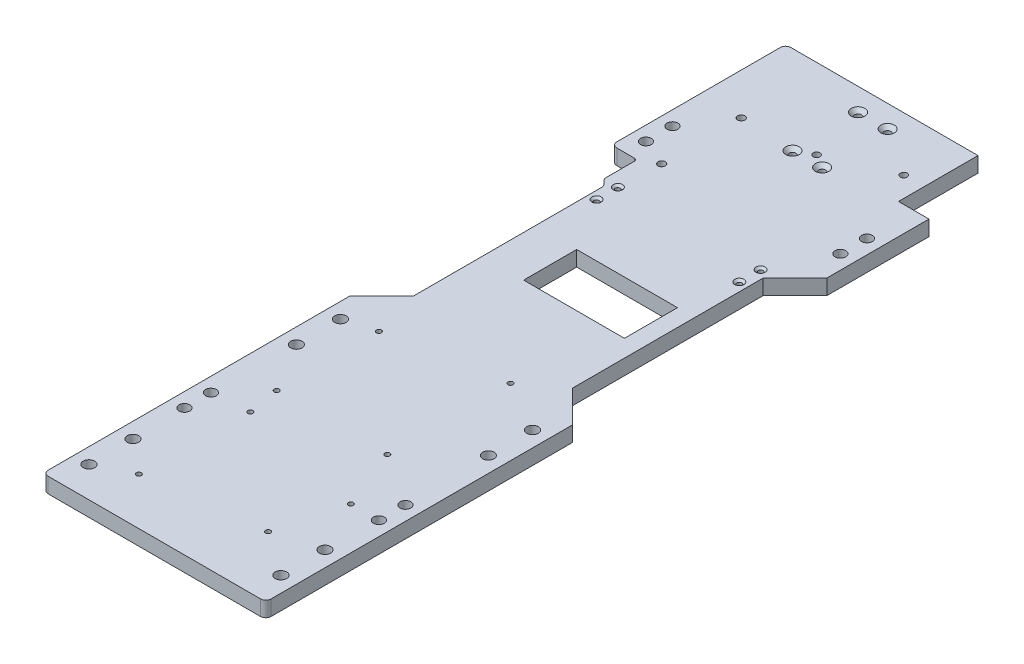
from build123d import *

# Parameters (mm, degrees)
SKETCH1_W                                         = 106.7435
SKETCH1_H                                         = 355.6
BOSS_EXTRUDE1_DEPTH                               = 7.3152
F_6_0_204_DIAMETER_HOLE1_D                        = 5.1816
FILLET1_R                                         = 2.54
MIRROR3_COPY_1_D                                  = 5.1816
CUT_EXTRUDE1_DEPTH                                = 8.3152
CSK_FOR_M2_FLAT_HEAD_MACHINE_SCREW7_D             = 2.4
CSK_FOR_M2_FLAT_HEAD_MACHINE_SCREW7_DEPTH         = 7.3152
CSK_FOR_M2_FLAT_HEAD_MACHINE_SCREW7_CSINK_D       = 4.4
CSK_FOR_M2_FLAT_HEAD_MACHINE_SCREW7_CSINK_ANGLE   = 90
CSK_FOR_4_FLAT_HEAD_SOCKET_CAP_SCREW2_D           = 3.2639
CSK_FOR_4_FLAT_HEAD_SOCKET_CAP_SCREW2_DEPTH       = 7.3152
CSK_FOR_4_FLAT_HEAD_SOCKET_CAP_SCREW2_CSINK_D     = 6.477
CSK_FOR_4_FLAT_HEAD_SOCKET_CAP_SCREW2_CSINK_ANGLE = 82
SKETCH38_R                                        = 1.75
CUT_EXTRUDE4_DEPTH                                = 8.3152
CSK_FOR_4_FLAT_HEAD_SOCKET_CAP_SCREW3_D           = 3.2639
CSK_FOR_4_FLAT_HEAD_SOCKET_CAP_SCREW3_DEPTH       = 7.3152
CSK_FOR_4_FLAT_HEAD_SOCKET_CAP_SCREW3_CSINK_D     = 6.477
CSK_FOR_4_FLAT_HEAD_SOCKET_CAP_SCREW3_CSINK_ANGLE = 82
CSK_FOR_M5_FLAT_HEAD_MACHINE_SCREW1_D             = 5.5
CSK_FOR_M5_FLAT_HEAD_MACHINE_SCREW1_CSINK_D       = 10.4
CSK_FOR_M5_FLAT_HEAD_MACHINE_SCREW1_CSINK_ANGLE   = 90
CUT_EXTRUDE7_DEPTH                                = 8.3152
FILLET5_R                                         = 2.54
FILLET6_R                                         = 1.27
CSK_FOR_M2_FLAT_HEAD_MACHINE_SCREW8_D             = 2.4
CSK_FOR_M2_FLAT_HEAD_MACHINE_SCREW8_DEPTH         = 7.3152
CSK_FOR_M2_FLAT_HEAD_MACHINE_SCREW8_CSINK_D       = 4.4
CSK_FOR_M2_FLAT_HEAD_MACHINE_SCREW8_CSINK_ANGLE   = 90
CSK_FOR_M2_FLAT_HEAD_MACHINE_SCREW9_D             = 2.4
CSK_FOR_M2_FLAT_HEAD_MACHINE_SCREW9_DEPTH         = 7.3152
CSK_FOR_M2_FLAT_HEAD_MACHINE_SCREW9_CSINK_D       = 4.4
CSK_FOR_M2_FLAT_HEAD_MACHINE_SCREW9_CSINK_ANGLE   = 90
SKETCH71_W                                        = 48.26
SKETCH71_H                                        = 25.4
CUT_EXTRUDE8_DEPTH                                = 8.3152
SKETCH75_W                                        = 14.593267778
SKETCH75_H                                        = 38.406883096
CUT_EXTRUDE10_DEPTH                               = 8.3152


with BuildPart() as part:
    # Sketch1 → Boss-Extrude1 (new body)
    with BuildSketch(Plane(origin=(0, 0, 0), x_dir=(1, 0, 0), z_dir=(0, 1, 0))):
        Rectangle(SKETCH1_W, SKETCH1_H)
    extrude(amount=BOSS_EXTRUDE1_DEPTH)

    # 6 _0.204_ Diameter Hole1 (through all)
    with Locations(Plane(origin=(-46.56135, 7.3152, 116.84), x_dir=(0, 0, 1), z_dir=(0, 1, 0))):
        with Locations((0, 0), (-12.7, 0)):
            f_6_0_204_diameter_hole1 = Hole(F_6_0_204_DIAMETER_HOLE1_D / 2)

    # Mirror2: 6 _0.204_ Diameter Hole1 across plane
    add(f_6_0_204_diameter_hole1.mirror(Plane(origin=(0, 0, 0), x_dir=(0, 0, 1), z_dir=(1, 0, 0))), mode=Mode.SUBTRACT)

    # Fillet1
    fillet1_edges = [part.edges().sort_by_distance(p)[0] for p in [
        (-53.37175, 3.6576, -177.8),
        (53.37175, 3.6576, -177.8),
        (53.37175, 3.6576, 177.8),
        (-53.37175, 3.6576, 177.8),
    ]]
    fillet(fillet1_edges, radius=FILLET1_R)

    # Mirror3: 6 _0.204_ Diameter Hole1 across plane
    add(f_6_0_204_diameter_hole1.mirror(Plane.XY), mode=Mode.SUBTRACT)

    # Mirror3 copy 1 (through all)
    with Locations(Plane(origin=(46.56135, 7.3152, -116.84), x_dir=(0, 0, -1), z_dir=(0, 1, 0))):
        with Locations((0, 0), (-12.7, 0)):
            Hole(MIRROR3_COPY_1_D / 2)

    # Sketch5 → Cut-Extrude1 (cut, through all)
    with BuildSketch(Plane(origin=(0, 7.3152, 0), x_dir=(1, 0, 0), z_dir=(0, 1, 0))):
        Polygon((-53.37175, 90.834626289), (-38.13175, 75.594626289), (-38.13175, -15.673529422), (-53.37175, -30.913529422), align=None)
    cut_extrude1 = extrude(amount=-CUT_EXTRUDE1_DEPTH, mode=Mode.SUBTRACT)

    # Mirror4: Cut-Extrude1 across plane
    add(cut_extrude1.mirror(Plane(origin=(0, 0, 0), x_dir=(0, 0, 1), z_dir=(1, 0, 0))), mode=Mode.SUBTRACT)

    # CSK for M2 Flat Head Machine Screw7
    with Locations(Plane(origin=(0, 0, 0), x_dir=(-1, 0, 0), z_dir=(0, -1, 0))):
        with Locations((-33.094268708, -116.815533429), (-24.794268708, -148.115533429), (30.005731292, -155.215533429), (29.105731292, -102.715533429)):
            CounterSinkHole(CSK_FOR_M2_FLAT_HEAD_MACHINE_SCREW7_D / 2, CSK_FOR_M2_FLAT_HEAD_MACHINE_SCREW7_CSINK_D / 2, depth=CSK_FOR_M2_FLAT_HEAD_MACHINE_SCREW7_DEPTH, counter_sink_angle=CSK_FOR_M2_FLAT_HEAD_MACHINE_SCREW7_CSINK_ANGLE)

    # CSK for _4 Flat Head Socket Cap Screw2
    with Locations(Plane(origin=(0, 0, 0), x_dir=(-1, 0, 0), z_dir=(0, -1, 0))):
        with Locations((0.183884754, 139.471736697), (-29.13583002, 151.916351018)):
            CounterSinkHole(CSK_FOR_4_FLAT_HEAD_SOCKET_CAP_SCREW2_D / 2, CSK_FOR_4_FLAT_HEAD_SOCKET_CAP_SCREW2_CSINK_D / 2, depth=CSK_FOR_4_FLAT_HEAD_SOCKET_CAP_SCREW2_DEPTH, counter_sink_angle=CSK_FOR_4_FLAT_HEAD_SOCKET_CAP_SCREW2_CSINK_ANGLE)

    # Sketch38 → Cut-Extrude4 (cut, through all)
    with BuildSketch(Plane(origin=(0, 7.3152, 0), x_dir=(1, 0, 0), z_dir=(0, 1, 0))):
        with Locations((-33.523663929, 136.737341699)):
            Circle(SKETCH38_R)
        with Locations((-33.523663929, 98.637341699)):
            Circle(SKETCH38_R)
    extrude(amount=-CUT_EXTRUDE4_DEPTH, mode=Mode.SUBTRACT)

    # CSK for _4 Flat Head Socket Cap Screw3
    with Locations(Plane(origin=(0, 7.3152, 0), x_dir=(1, 0, 0), z_dir=(0, 1, 0))):
        with Locations((-7.889924556, 167.050416778), (6.108061578, 167.170302445), (6.410944313, 135.537767156), (-7.650969292, 135.417333982)):
            CounterSinkHole(CSK_FOR_4_FLAT_HEAD_SOCKET_CAP_SCREW3_D / 2, CSK_FOR_4_FLAT_HEAD_SOCKET_CAP_SCREW3_CSINK_D / 2, depth=CSK_FOR_4_FLAT_HEAD_SOCKET_CAP_SCREW3_DEPTH, counter_sink_angle=CSK_FOR_4_FLAT_HEAD_SOCKET_CAP_SCREW3_CSINK_ANGLE)

    # CSK for M5 Flat Head Machine Screw1 (through all)
    with Locations(Plane(origin=(0, 0, 0), x_dir=(-1, 0, 0), z_dir=(0, -1, 0))):
        with Locations((-45.931559494, -42.674414725), (-45.931559494, -63.774414725), (46.018440506, -63.774414725), (46.018440506, -42.674414725), (-45.931559494, -142.024414725), (-45.931559494, -163.124414725), (46.018440506, -142.024414725), (46.018440506, -163.124414725)):
            CounterSinkHole(CSK_FOR_M5_FLAT_HEAD_MACHINE_SCREW1_D / 2, CSK_FOR_M5_FLAT_HEAD_MACHINE_SCREW1_CSINK_D / 2, counter_sink_angle=CSK_FOR_M5_FLAT_HEAD_MACHINE_SCREW1_CSINK_ANGLE)

    # Sketch64 → Cut-Extrude7 (cut, through all)
    with BuildSketch(Plane.XZ):
        Polygon((-53.37175, -90.834626289), (-41.127432306, -78.590308595), (-41.127432306, -94.46979617), (-53.37175, -94.46979617), align=None)
    extrude(amount=-CUT_EXTRUDE7_DEPTH, mode=Mode.SUBTRACT)

    # Fillet5
    fillet5_edges = [part.edges().sort_by_distance(p)[0] for p in [
        (-53.37175, 3.6576, -94.46979617),
        (-41.127432306, 3.6576, -78.590308595),
        (-38.13175, 3.6576, -75.594626289),
    ]]
    fillet(fillet5_edges, radius=FILLET5_R)

    # Fillet6
    fillet6_edges = [part.edges().sort_by_distance(p)[0] for p in [
        (-41.127432306, 3.6576, -94.46979617),
    ]]
    fillet(fillet6_edges, radius=FILLET6_R)

    # CSK for M2 Flat Head Machine Screw8
    with Locations(Plane(origin=(0, 0, 0), x_dir=(-1, 0, 0), z_dir=(0, -1, 0))):
        with Locations((-21.314354188, -28.557533429), (-21.314354188, -87.557533429), (31.685645812, -87.557533429), (31.685645812, -38.557533429)):
            CounterSinkHole(CSK_FOR_M2_FLAT_HEAD_MACHINE_SCREW8_D / 2, CSK_FOR_M2_FLAT_HEAD_MACHINE_SCREW8_CSINK_D / 2, depth=CSK_FOR_M2_FLAT_HEAD_MACHINE_SCREW8_DEPTH, counter_sink_angle=CSK_FOR_M2_FLAT_HEAD_MACHINE_SCREW8_CSINK_ANGLE)

    # CSK for M2 Flat Head Machine Screw9
    with Locations(Plane(origin=(0, 7.3152, 0), x_dir=(1, 0, 0), z_dir=(0, 1, 0))):
        with Locations((-34.319660017, 78.441117031), (-34.319660017, 68.250966377), (34.038339983, 78.441117031), (34.038339983, 68.250966377)):
            CounterSinkHole(CSK_FOR_M2_FLAT_HEAD_MACHINE_SCREW9_D / 2, CSK_FOR_M2_FLAT_HEAD_MACHINE_SCREW9_CSINK_D / 2, depth=CSK_FOR_M2_FLAT_HEAD_MACHINE_SCREW9_DEPTH, counter_sink_angle=CSK_FOR_M2_FLAT_HEAD_MACHINE_SCREW9_CSINK_ANGLE)

    # Sketch71 → Cut-Extrude8 (cut, through all)
    with BuildSketch(Plane(origin=(0, 7.3152, 0), x_dir=(1, 0, 0), z_dir=(0, 1, 0))):
        with Locations((5.78359778, 30.072466952)):
            Rectangle(SKETCH71_W, SKETCH71_H)
    extrude(amount=-CUT_EXTRUDE8_DEPTH, mode=Mode.SUBTRACT)

    # Sketch75 → Cut-Extrude10 (cut, through all)
    with BuildSketch(Plane(origin=(0, 7.3152, 0), x_dir=(1, 0, 0), z_dir=(0, 1, 0))):
        with Locations((46.075116111, 158.934987952)):
            Rectangle(SKETCH75_W, SKETCH75_H)
    extrude(amount=-CUT_EXTRUDE10_DEPTH, mode=Mode.SUBTRACT)


solid = part.part
